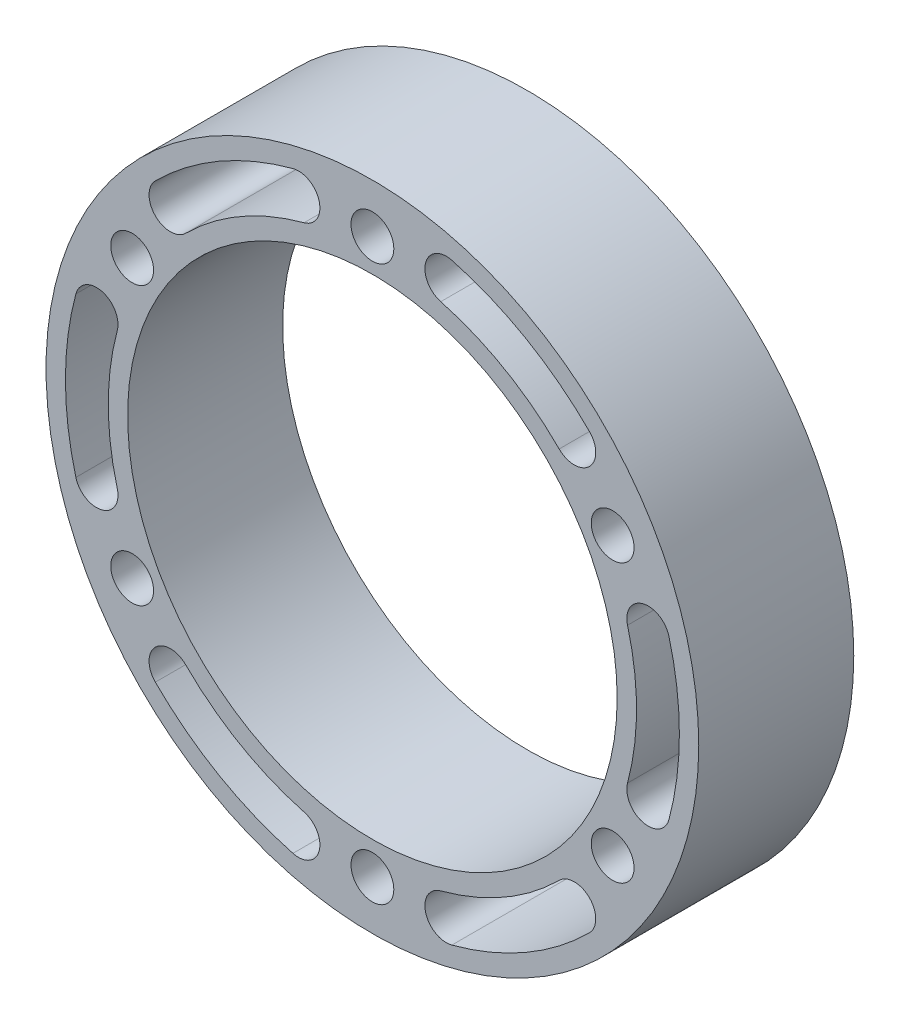
from build123d import *

# Parameters (mm, degrees)
SKETCH1_R           = 40
SKETCH1_R_2         = 30
SKETCH1_R_3         = 2.625
BOSS_EXTRUDE1_DEPTH = 19


with BuildPart() as part:
    # Sketch1 → Boss-Extrude1 (new body)
    with BuildSketch(Plane.XY):
        Circle(SKETCH1_R)
        Circle(SKETCH1_R_2, mode=Mode.SUBTRACT)
        with Locations((0, 34)):
            Circle(SKETCH1_R_3, mode=Mode.SUBTRACT)
        with Locations((29.444863729, 17)):
            Circle(SKETCH1_R_3, mode=Mode.SUBTRACT)
        with Locations((29.444863729, -17)):
            Circle(SKETCH1_R_3, mode=Mode.SUBTRACT)
        with Locations((0, -34)):
            Circle(SKETCH1_R_3, mode=Mode.SUBTRACT)
        with Locations((-29.444863729, -17)):
            Circle(SKETCH1_R_3, mode=Mode.SUBTRACT)
        with Locations((-29.444863729, 17)):
            Circle(SKETCH1_R_3, mode=Mode.SUBTRACT)
        with BuildLine():
            ThreePointArc((-9.738066572, 36.342959214), (-18.8125, 32.584205817), (-26.604892642, 26.604892642))
            ThreePointArc((-26.604892642, 26.604892642), (-26.604892642, 22.892582041), (-22.892582041, 22.892582041))
            ThreePointArc((-22.892582041, 22.892582041), (-16.1875, 28.037572448), (-8.379266585, 31.271848626))
            ThreePointArc((-8.379266585, 31.271848626), (-6.523111285, 34.486803914), (-9.738066572, 36.342959214))
        make_face(mode=Mode.SUBTRACT)
        with BuildLine():
            ThreePointArc((26.604892642, 26.604892642), (18.8125, 32.584205817), (9.738066572, 36.342959214))
            ThreePointArc((9.738066572, 36.342959214), (6.523111285, 34.486803914), (8.379266585, 31.271848626))
            ThreePointArc((8.379266585, 31.271848626), (16.1875, 28.037572448), (22.892582041, 22.892582041))
            ThreePointArc((22.892582041, 22.892582041), (26.604892642, 22.892582041), (26.604892642, 26.604892642))
        make_face(mode=Mode.SUBTRACT)
        with BuildLine():
            ThreePointArc((36.342959214, -9.738066572), (37.625, 0), (36.342959214, 9.738066572))
            ThreePointArc((36.342959214, 9.738066572), (33.128003927, 11.594221873), (31.271848626, 8.379266585))
            ThreePointArc((31.271848626, 8.379266585), (32.375, 0), (31.271848626, -8.379266585))
            ThreePointArc((31.271848626, -8.379266585), (33.128003927, -11.594221873), (36.342959214, -9.738066572))
        make_face(mode=Mode.SUBTRACT)
        with BuildLine():
            ThreePointArc((9.738066572, -36.342959214), (18.8125, -32.584205817), (26.604892642, -26.604892642))
            ThreePointArc((26.604892642, -26.604892642), (26.604892642, -22.892582041), (22.892582041, -22.892582041))
            ThreePointArc((22.892582041, -22.892582041), (16.1875, -28.037572448), (8.379266585, -31.271848626))
            ThreePointArc((8.379266585, -31.271848626), (6.523111285, -34.486803914), (9.738066572, -36.342959214))
        make_face(mode=Mode.SUBTRACT)
        with BuildLine():
            ThreePointArc((-26.604892642, -26.604892642), (-18.8125, -32.584205817), (-9.738066572, -36.342959214))
            ThreePointArc((-9.738066572, -36.342959214), (-6.523111285, -34.486803914), (-8.379266585, -31.271848626))
            ThreePointArc((-8.379266585, -31.271848626), (-16.1875, -28.037572448), (-22.892582041, -22.892582041))
            ThreePointArc((-22.892582041, -22.892582041), (-26.604892642, -22.892582041), (-26.604892642, -26.604892642))
        make_face(mode=Mode.SUBTRACT)
        with BuildLine():
            ThreePointArc((-36.342959214, 9.738066572), (-37.625, 0), (-36.342959214, -9.738066572))
            ThreePointArc((-36.342959214, -9.738066572), (-33.128003927, -11.594221873), (-31.271848626, -8.379266585))
            ThreePointArc((-31.271848626, -8.379266585), (-32.375, 0), (-31.271848626, 8.379266585))
            ThreePointArc((-31.271848626, 8.379266585), (-33.128003927, 11.594221873), (-36.342959214, 9.738066572))
        make_face(mode=Mode.SUBTRACT)
    extrude(amount=BOSS_EXTRUDE1_DEPTH)


solid = part.part
